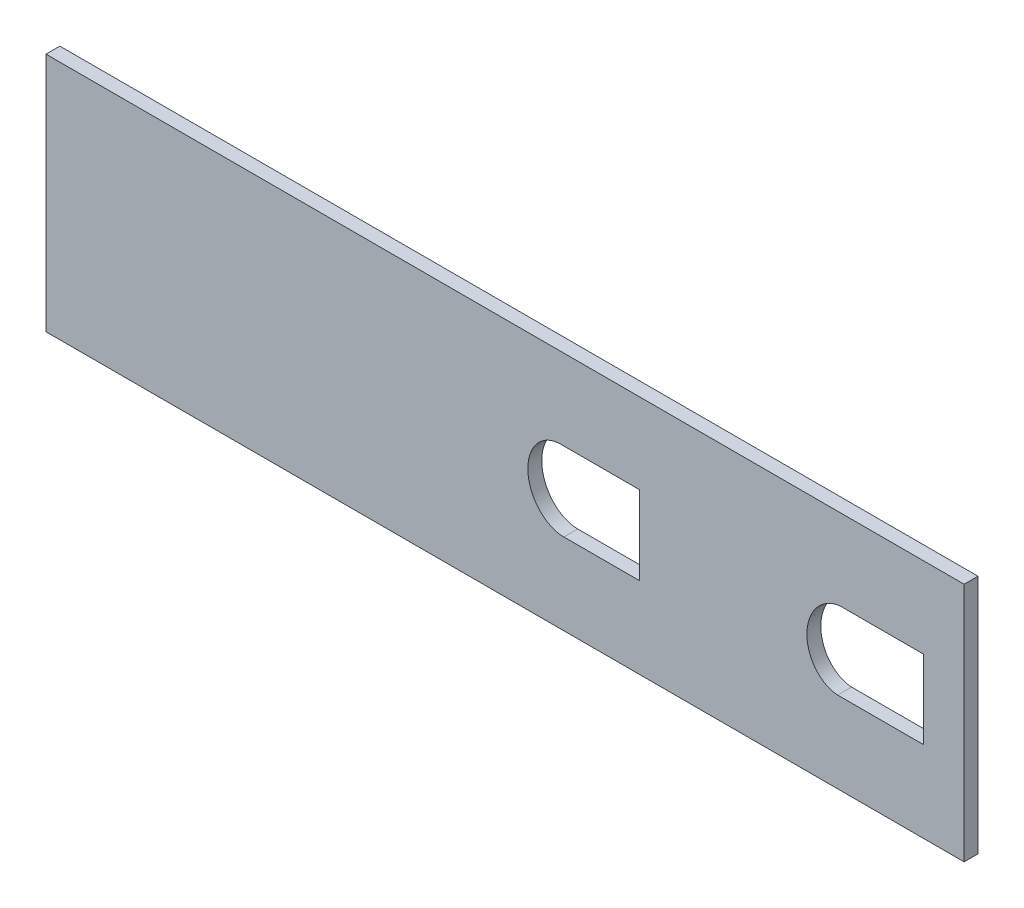
from build123d import *

# Parameters (mm, degrees)
SKETCH1_W           = 210
SKETCH1_H           = 55
BOSS_EXTRUDE1_DEPTH = 3.175


with BuildPart() as part:
    # Sketch1 → Boss-Extrude1 (new body)
    with BuildSketch(Plane.XY):
        with Locations((-261.58829827, -18.441689147)):
            Rectangle(SKETCH1_W, SKETCH1_H)
        with BuildLine():
            Line((-183.826005128, -9.437626279), (-165.825906922, -9.437626279))
            Line((-165.825906922, -9.437626279), (-165.825906922, -27.359682536))
            Line((-165.825906922, -27.359682536), (-185.498112528, -27.359682536))
            add(Edge.make_bspline(
                [(-183.826005128, -9.437626279), (-184.381626607, -9.397687719), (-184.930515996, -9.424835034), (-186.015461991, -9.607009465), (-186.554689235, -9.764877403), (-187.316224975, -10.082704779), (-187.563814734, -10.202332624), (-188.04695947, -10.467917292), (-188.283591247, -10.614653216), (-188.967244505, -11.088099477), (-189.385834671, -11.445153232), (-190.155876141, -12.234064044), (-190.507940946, -12.668506087), (-191.124349263, -13.579620928), (-191.392257861, -14.05945224), (-191.73522916, -14.814675279), (-191.839717206, -15.072804389), (-192.025673908, -15.592230911), (-192.107659089, -15.854561779), (-192.321609275, -16.649175241), (-192.421750284, -17.189035513), (-192.508320777, -18.013979615), (-192.526449679, -18.291627862), (-192.540341709, -18.842430921), (-192.536260587, -19.116785649), (-192.490788714, -19.936695463), (-192.416446167, -20.47912245), (-192.234051872, -21.286034277), (-192.160881012, -21.555192562), (-191.992478644, -22.081128913), (-191.89721521, -22.338632762), (-191.57815234, -23.094708941), (-191.321465438, -23.577036127), (-190.86409563, -24.264793996), (-190.698255397, -24.489466796), (-190.347004112, -24.917221829), (-190.161879434, -25.120329067), (-189.577727686, -25.697021795), (-189.150303695, -26.038410046), (-188.444997142, -26.47773401), (-188.199013121, -26.611592551), (-187.699838217, -26.845624837), (-187.189859794, -27.048393537), (-186.658261328, -27.188597437), (-186.115554078, -27.296654363), (-185.837627103, -27.33444368), (-185.540644376, -27.356776903), (-185.519377345, -27.358278606), (-185.498112528, -27.359682536)],
                knots=[0, 0, 0, 0, 0.03125, 0.03125, 0.0625, 0.0625, 0.078125, 0.078125, 0.09375, 0.09375, 0.125, 0.125, 0.15625, 0.15625, 0.1875, 0.1875, 0.203125, 0.203125, 0.21875, 0.21875, 0.25, 0.25, 0.265625, 0.265625, 0.28125, 0.28125, 0.3125, 0.3125, 0.328125, 0.328125, 0.34375, 0.34375, 0.375, 0.375, 0.390625, 0.390625, 0.40625, 0.40625, 0.4375, 0.4375, 0.453125, 0.453125, 0.46875, 0.484375, 0.484375, 0.5, 0.5, 0.501205353, 0.501205353, 0.501205353, 0.501205353], degree=3))
        make_face(mode=Mode.SUBTRACT)
        with BuildLine():
            Line((-248.842639606, -9.34526812), (-230.842639606, -9.34526812))
            Line((-230.842639606, -9.34526812), (-230.842639606, -27.359569421))
            Line((-230.842639606, -27.359569421), (-248.122030426, -27.359569421))
            add(Edge.make_bspline(
                [(-248.842639606, -9.34526812), (-249.008492971, -9.34526812), (-249.174528912, -9.351217217), (-249.897892737, -9.403148293), (-250.439041218, -9.508791349), (-251.226902991, -9.764277117), (-251.486942339, -9.866389631), (-251.991898718, -10.100883467), (-252.478538383, -10.363667412), (-252.930635604, -10.679802053), (-253.365916766, -11.021909044), (-253.576181816, -11.207074635), (-254.170571266, -11.790206392), (-254.521054547, -12.216408682), (-254.984007031, -12.907063712), (-255.128207339, -13.146926319), (-255.391039985, -13.635131957), (-255.510280092, -13.884200022), (-255.833281599, -14.645561933), (-256.003111783, -15.174210606), (-256.250113173, -16.258400348), (-256.325565617, -16.804580713), (-256.371925399, -17.6295328), (-256.376170681, -17.905469832), (-256.362395823, -18.459237102), (-256.344221579, -18.737973637), (-256.257616038, -19.564249546), (-256.157308421, -20.105224546), (-255.942745346, -20.901816623), (-255.860495563, -21.164858437), (-255.673862588, -21.685807516), (-255.568906935, -21.944849427), (-255.224992289, -22.701497667), (-254.956918189, -23.181017599), (-254.49602176, -23.862551099), (-254.33253309, -24.083399995), (-253.984921716, -24.511848542), (-253.79988931, -24.720372449), (-253.217915831, -25.317918038), (-252.799712482, -25.674443478), (-252.12529242, -26.144005131), (-251.892576917, -26.289576641), (-251.410235402, -26.557308591), (-251.158897378, -26.680166876), (-250.389777098, -27.004646057), (-249.862976161, -27.161019247), (-249.050989853, -27.302657737), (-248.776672466, -27.334279323), (-248.37319776, -27.356189189), (-248.247527215, -27.359569421), (-248.122030426, -27.359569421)],
                knots=[0.990687447, 0.990687447, 0.990687447, 0.990687447, 1, 1, 1.03125, 1.03125, 1.046875, 1.046875, 1.0625, 1.078125, 1.078125, 1.09375, 1.09375, 1.125, 1.125, 1.140625, 1.140625, 1.15625, 1.15625, 1.1875, 1.1875, 1.21875, 1.21875, 1.234375, 1.234375, 1.25, 1.25, 1.28125, 1.28125, 1.296875, 1.296875, 1.3125, 1.3125, 1.34375, 1.34375, 1.359375, 1.359375, 1.375, 1.375, 1.40625, 1.40625, 1.421875, 1.421875, 1.4375, 1.4375, 1.46875, 1.46875, 1.484375, 1.484375, 1.491411882, 1.491411882, 1.491411882, 1.491411882], degree=3))
        make_face(mode=Mode.SUBTRACT)
    extrude(amount=BOSS_EXTRUDE1_DEPTH)


solid = part.part
